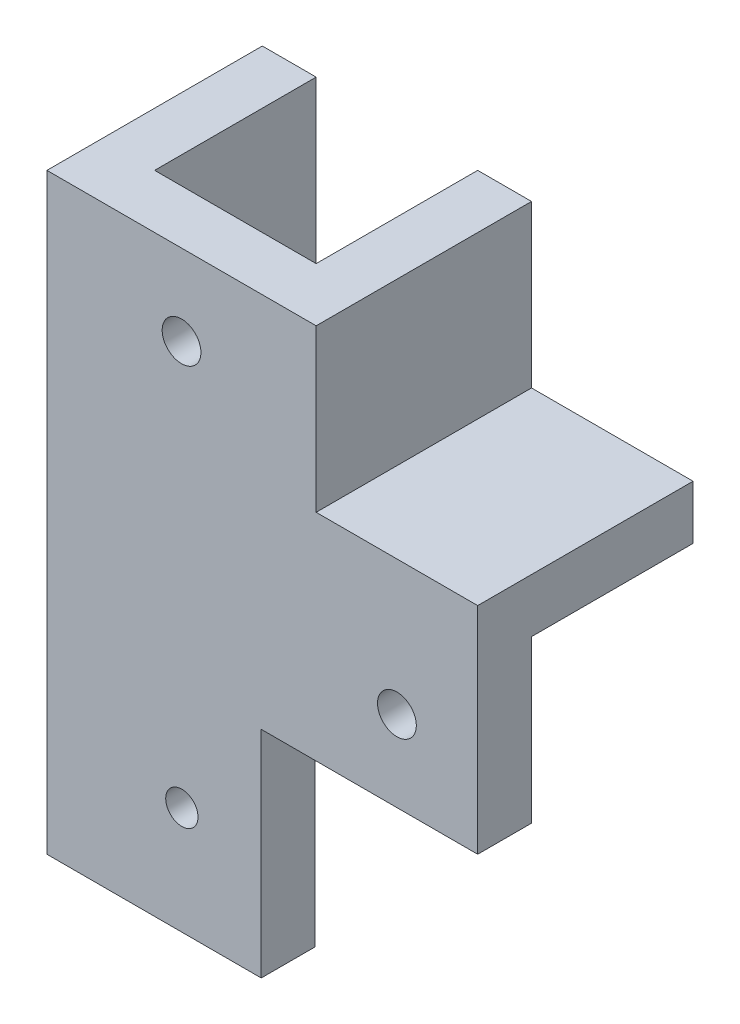
from build123d import *

# Parameters (mm, degrees)
BOSS_EXTRUDE1_DEPTH = 5
BOSS_EXTRUDE2_DEPTH = 15
BOSS_EXTRUDE3_DEPTH = 15
SKETCH4_R           = 1.8
CUT_EXTRUDE1_DEPTH  = 6
SKETCH6_W           = 14.9
SKETCH6_H           = 20
BOSS_EXTRUDE4_DEPTH = 5
SKETCH8_R           = 1.5
CUT_EXTRUDE3_DEPTH  = 21
SKETCH9_W           = 5
SKETCH9_H           = 55
BOSS_EXTRUDE5_DEPTH = 5
BOSS_EXTRUDE6_DEPTH = 5


with BuildPart() as part:
    # Sketch1 → Boss-Extrude1 (new body)
    with BuildSketch(Plane.XY):
        Polygon((7.370119522, -25.806772908), (27.470119522, -25.806772908), (27.470119522, -10.806772908), (7.470119522, -10.806772908), (7.470119522, 9.193227092), (-7.529880478, 9.193227092), (-7.529880478, -25.806772908), align=None)
    extrude(amount=BOSS_EXTRUDE1_DEPTH)

    # Sketch4 → Cut-Extrude1 (cut, through all)
    with BuildSketch(Plane(origin=(0, 0, 0), x_dir=(-1, 0, 0), z_dir=(0, 0, -1))):
        with Locations((0.029880478, 1.693227092)):
            Circle(SKETCH4_R)
        with Locations((-19.970119522, -18.306772908)):
            Circle(SKETCH4_R)
    extrude(amount=-CUT_EXTRUDE1_DEPTH, mode=Mode.SUBTRACT)

    # Sketch6 → Boss-Extrude4 (add)
    with BuildSketch(Plane.XY.offset(5)):
        with Locations((-0.079880478, -35.806772908)):
            Rectangle(SKETCH6_W, SKETCH6_H)
    extrude(amount=-BOSS_EXTRUDE4_DEPTH)

    # Sketch8 → Cut-Extrude3 (cut, through all)
    with BuildSketch(Plane.XY.offset(5)):
        with Locations((0, -35.806772908)):
            Circle(SKETCH8_R)
    extrude(amount=-CUT_EXTRUDE3_DEPTH, mode=Mode.SUBTRACT)



with BuildPart() as body_2:
    # Sketch2 → Boss-Extrude2 (new body)
    with BuildSketch(Plane(origin=(0, 0, 0), x_dir=(-1, 0, 0), z_dir=(0, 0, -1))):
        Polygon((-7.470119522, 9.193227092), (-12.470119522, 9.193227092), (-12.470119522, -5.806772908), (-27.470119522, -5.806772908), (-27.470119522, -10.806772908), (-7.470119522, -10.806772908), align=None)
    extrude(amount=BOSS_EXTRUDE2_DEPTH)


with BuildPart() as body_3:
    # Sketch3 → Boss-Extrude3 (new body)
    with BuildSketch(Plane(origin=(0, 0, 0), x_dir=(-1, 0, 0), z_dir=(0, 0, -1))):
        Polygon((7.529880478, 9.193227092), (12.529880478, 9.193227092), (12.529880478, -45.806772908), (7.529880478, -45.806772908), (7.529880478, -25.806772908), align=None)
    extrude(amount=BOSS_EXTRUDE3_DEPTH)


with BuildPart() as part_1:
    add(part.part)

    add(body_3.part)  # Boss-Extrude5 merges body 3
    # Sketch9 → Boss-Extrude5 (add)
    with BuildSketch(Plane.XY.offset(5)):
        with Locations((-10.029880478, -18.306772908)):
            Rectangle(SKETCH9_W, SKETCH9_H)
    extrude(amount=-BOSS_EXTRUDE5_DEPTH)


    add(body_2.part)  # Boss-Extrude6 merges body 2
    # Sketch10 → Boss-Extrude6 (add)
    with BuildSketch(Plane.XY):
        Polygon((7.470119522, 9.193227092), (12.470119522, 9.193227092), (12.470119522, -5.806772908), (27.470119522, -5.806772908), (27.470119522, -10.806772908), (7.470119522, -10.806772908), align=None)
    extrude(amount=BOSS_EXTRUDE6_DEPTH)


solid = part_1.part
